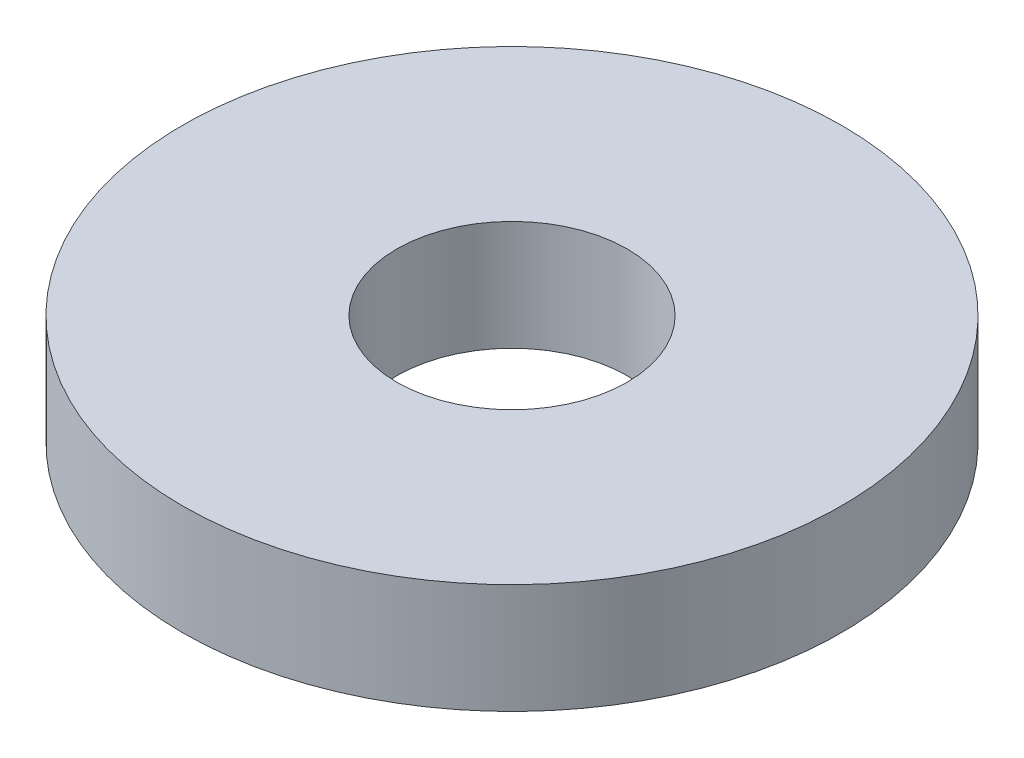
from build123d import *

# Parameters (mm, degrees)
SKETCH_1_R      = 6
SKETCH_1_R_2    = 2.1
EXTRUDE_1_DEPTH = 2


with BuildPart() as part:
    # Эскиз1 → Бобышка-Вытянуть1 (new body)
    with BuildSketch(Plane(origin=(0, 0, 0), x_dir=(1, 0, 0), z_dir=(0, 1, 0))):
        Circle(SKETCH_1_R)
        Circle(SKETCH_1_R_2, mode=Mode.SUBTRACT)
    extrude(amount=EXTRUDE_1_DEPTH)


solid = part.part
